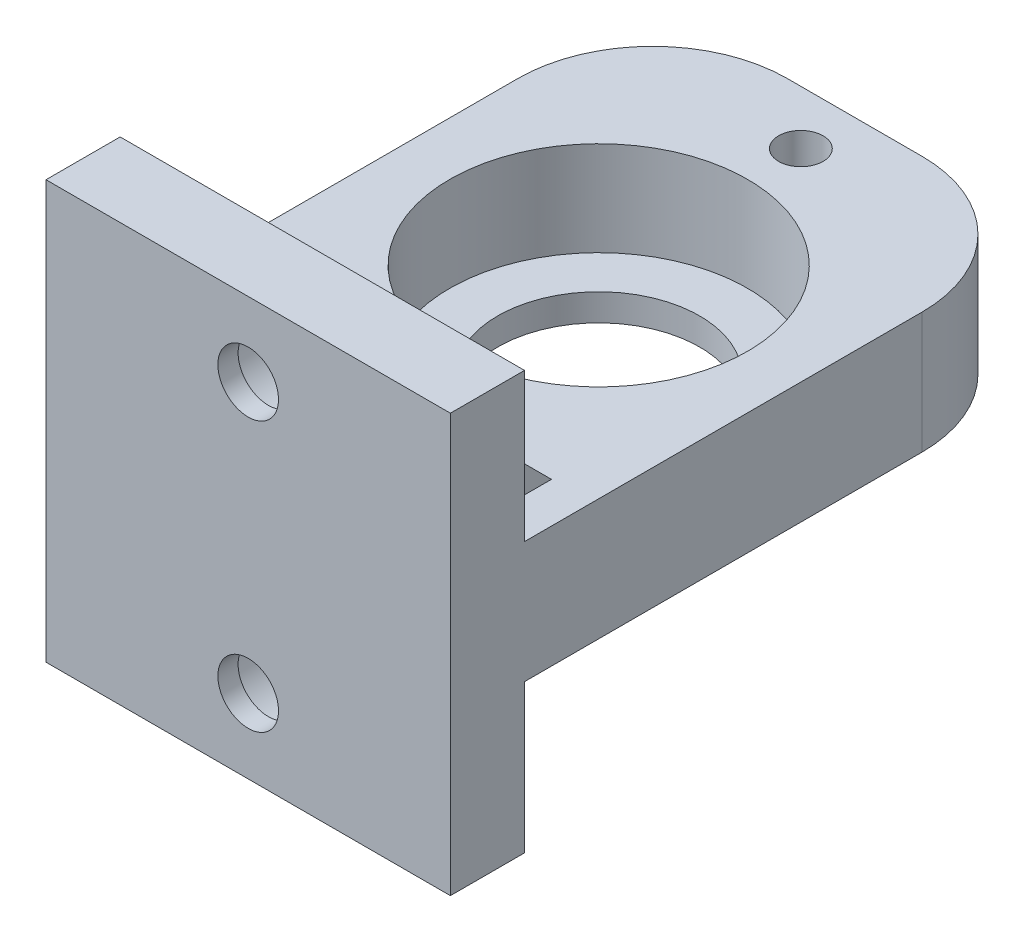
from build123d import *

# Parameters (mm, degrees)
SKETCH2_W                      = 30
SKETCH2_H                      = 45
BOSS_EXTRUDE1_DEPTH            = 9
SKETCH3_R                      = 11.05
CUT_EXTRUDE1_DEPTH             = 7
SKETCH4_R                      = 7.5
CUT_EXTRUDE2_DEPTH             = 28.932955447
FILLET1_R                      = 10
SKETCH5_W                      = 30
SKETCH5_H                      = 11
BOSS_EXTRUDE2_DEPTH            = 5.5
CBORE_FOR_M4_SHCS1_D           = 4.5
CBORE_FOR_M4_SHCS1_CBORE_D     = 8
CBORE_FOR_M4_SHCS1_CBORE_DEPTH = 4
RIB1_REACH                     = 37.387
SKETCH10_WALL_W                = 79.845356928
SKETCH10_WALL_H                = 4
F_3_3_3_3_DIAMETER_HOLE1_D     = 3.3
F_3_3_3_3_DIAMETER_HOLE1_DEPTH = 5
F_3_3_3_3_DIAMETER_HOLE1_TIP   = 0.991420021
SKETCH14_W                     = 30
SKETCH14_H                     = 5.5
BOSS_EXTRUDE3_DEPTH            = 11
MIRROR2_COPY_1_REACH           = 37.387
MIRROR2_COPY_1_SKETCH_W        = 79.845356928
MIRROR2_COPY_1_SKETCH_H        = 4


with BuildPart() as part:
    # Sketch2 → Boss-Extrude1 (new body)
    with BuildSketch(Plane(origin=(0, 0, 0), x_dir=(1, 0, 0), z_dir=(0, 1, 0))):
        Rectangle(SKETCH2_W, SKETCH2_H)
    extrude(amount=BOSS_EXTRUDE1_DEPTH)

    # Sketch3 → Cut-Extrude1 (cut)
    with BuildSketch(Plane(origin=(0, 9, 0), x_dir=(1, 0, 0), z_dir=(0, 1, 0))):
        with Locations(Location((0, 3.5, 0), (0, 0, 270))):
            Circle(SKETCH3_R)
    extrude(amount=-CUT_EXTRUDE1_DEPTH, mode=Mode.SUBTRACT)

    # Sketch4 → Cut-Extrude2 (cut, through all)
    with BuildSketch(Plane(origin=(0, 2, 0), x_dir=(1, 0, 0), z_dir=(0, 1, 0))):
        with Locations(Location((0, 3.5, 0), (0, 0, 270))):
            Circle(SKETCH4_R)
    extrude(amount=-CUT_EXTRUDE2_DEPTH, mode=Mode.SUBTRACT)

    # Fillet1
    fillet1_edges = [part.edges().sort_by_distance(p)[0] for p in [
        (-15, 4.5, -22.5),
        (15, 4.5, -22.5),
    ]]
    fillet(fillet1_edges, radius=FILLET1_R)

    # Sketch5 → Boss-Extrude2 (add)
    with BuildSketch(Plane.XY.offset(22.5)):
        with Locations((0, -5.5)):
            Rectangle(SKETCH5_W, SKETCH5_H)
    extrude(amount=-BOSS_EXTRUDE2_DEPTH)

    # CBORE for M4 SHCS1 (through all)
    with Locations(Plane(origin=(0, 0, 17), x_dir=(-1, 0, 0), z_dir=(0, 0, -1))):
        with Locations((0, -5.5)):
            cbore_for_m4_shcs1 = CounterBoreHole(CBORE_FOR_M4_SHCS1_D / 2, CBORE_FOR_M4_SHCS1_CBORE_D / 2, CBORE_FOR_M4_SHCS1_CBORE_DEPTH)

    # Sketch10 wall → Rib1 (add, up to next)
    with BuildSketch(Plane(origin=(-10, -2.5, 14.5), x_dir=(0, -0.707106781187, 0.707106781187), z_dir=(0, 0.707106781187, 0.707106781187)), mode=Mode.PRIVATE) as rib1_sk1:
        Rectangle(SKETCH10_WALL_W, SKETCH10_WALL_H)
    rib1_tool1 = extrude(rib1_sk1.sketch, amount=RIB1_REACH, mode=Mode.PRIVATE) - part.part
    rib1 = rib1_tool1.solids().sort_by_distance((-10, -2.5, 14.5))[0]
    add(rib1)

    # Mirror1: Rib1 across plane
    add(rib1.mirror(Plane(origin=(0, 0, 0), x_dir=(0, 0, 1), z_dir=(1, 0, 0))))

    # Ø3.3 (3.3) Diameter Hole1
    with Locations(Plane(origin=(0, 9, 0), x_dir=(1, 0, 0), z_dir=(0, 1, 0))):
        with Locations((0, -11.5), (0, 3.5), (0, 18.5)):
            Hole(F_3_3_3_3_DIAMETER_HOLE1_D / 2, depth=F_3_3_3_3_DIAMETER_HOLE1_DEPTH)
            with Locations((0, 0, -(F_3_3_3_3_DIAMETER_HOLE1_DEPTH + F_3_3_3_3_DIAMETER_HOLE1_TIP / 2))):  # 118° drill point
                Cone(0, F_3_3_3_3_DIAMETER_HOLE1_D / 2, F_3_3_3_3_DIAMETER_HOLE1_TIP, mode=Mode.SUBTRACT)

    # Sketch14 → Boss-Extrude3 (add)
    with BuildSketch(Plane(origin=(0, 9, 0), x_dir=(1, 0, 0), z_dir=(0, 1, 0))):
        with Locations((0, -19.75)):
            Rectangle(SKETCH14_W, SKETCH14_H)
    extrude(amount=BOSS_EXTRUDE3_DEPTH)

    # Mirror2: Rib1 across plane
    add(rib1.mirror(Plane(origin=(0, 4.5, 0), x_dir=(0, 0, 1), z_dir=(0, -1, 0))))

    # Mirror2 copy 1 sketch → Mirror2 copy 1 (add, up to next)
    with BuildSketch(Plane(origin=(10, 11.5, 14.5), x_dir=(0, 0.707106781187, 0.707106781187), z_dir=(0, -0.707106781187, 0.707106781187)), mode=Mode.PRIVATE) as mirror2_copy_1_sk1:
        Rectangle(MIRROR2_COPY_1_SKETCH_W, MIRROR2_COPY_1_SKETCH_H)
    mirror2_copy_1_tool1 = extrude(mirror2_copy_1_sk1.sketch, amount=MIRROR2_COPY_1_REACH, mode=Mode.PRIVATE) - part.part
    add(mirror2_copy_1_tool1.solids().sort_by_distance((10, 11.5, 14.5))[0])

    # Mirror3: CBORE for M4 SHCS1 across plane
    add(cbore_for_m4_shcs1.mirror(Plane(origin=(0, 4.5, 0), x_dir=(0, 0, 1), z_dir=(0, -1, 0))), mode=Mode.SUBTRACT)


solid = part.part
